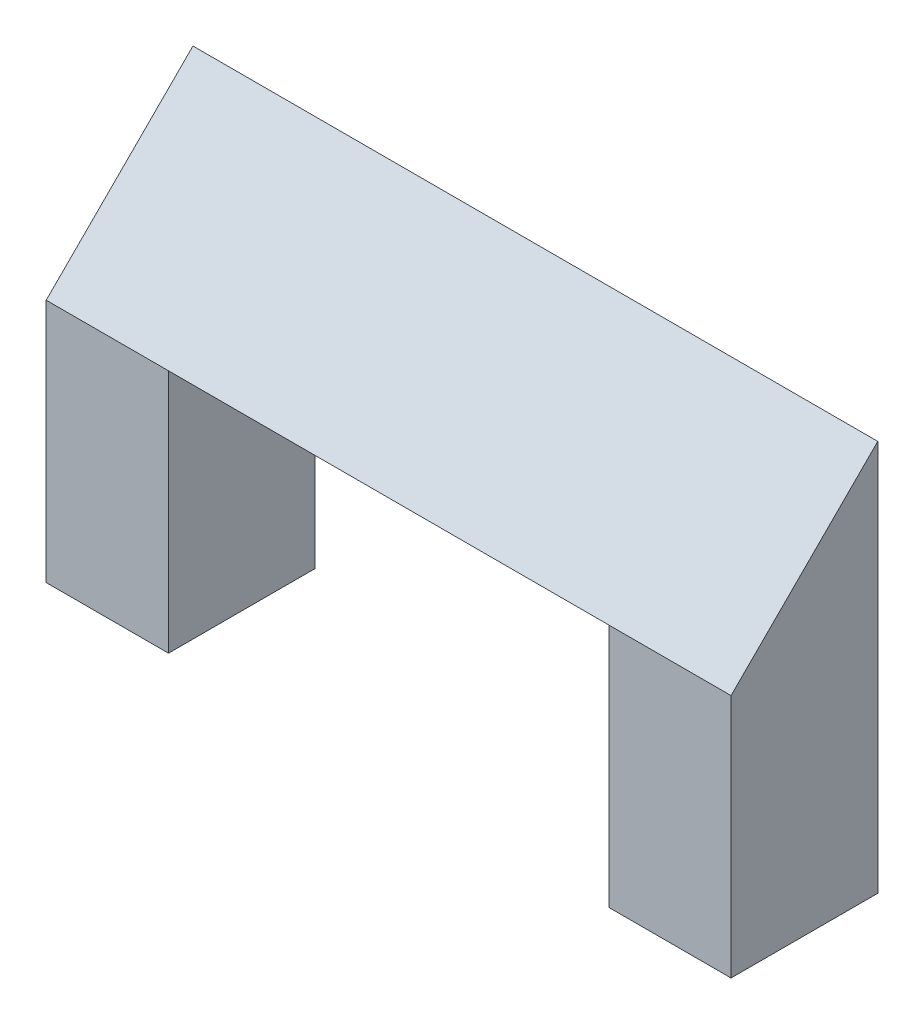
from build123d import *

# Parameters (mm, degrees)
SKETCH1_W             = 25
SKETCH1_H             = 30
BOSS_EXTRUDE1_DEPTH   = 50
BOSS_EXTRUDE1_2_DEPTH = 50
BOSS_EXTRUDE2_START   = -140
BOSS_EXTRUDE2_DEPTH   = 140
BOSS_EXTRUDE3_DEPTH   = 90


with BuildPart() as part:
    # Sketch1 → Boss-Extrude1 (new body)
    with BuildSketch(Plane(origin=(0, 0, 0), x_dir=(1, 0, 0), z_dir=(0, 1, 0))):
        with Locations((-31.032110092, 2.339449541)):
            Rectangle(SKETCH1_W, SKETCH1_H)
    extrude(amount=BOSS_EXTRUDE1_DEPTH)



with BuildPart() as body_2:
    # Sketch1 → Boss-Extrude1 2 (new body)
    with BuildSketch(Plane(origin=(0, 0, 0), x_dir=(1, 0, 0), z_dir=(0, 1, 0))):
        with Locations((83.967889908, 2.339449541)):
            Rectangle(SKETCH1_W, SKETCH1_H)
    extrude(amount=BOSS_EXTRUDE1_2_DEPTH)


with BuildPart() as part_1:
    add(part.part)

    add(body_2.part)  # Boss-Extrude2 merges body 2
    # Sketch2 → Boss-Extrude2 (add)
    with BuildSketch(Plane(origin=(96.467889908, 0, 0), x_dir=(0, 0, -1), z_dir=(1, 0, 0)).offset(BOSS_EXTRUDE2_START)):
        Polygon((-12.660550459, 50), (17.339449541, 50), (17.339449541, 80), align=None)
    extrude(amount=BOSS_EXTRUDE2_DEPTH)

    # Sketch3 → Boss-Extrude3 (add)
    with BuildSketch(Plane(origin=(-18.532110092, 0, 0), x_dir=(0, 0, -1), z_dir=(1, 0, 0))):
        Polygon((-12.660550459, 50), (17.339449541, 39.080892972), (17.339449541, 50), align=None)
    extrude(amount=BOSS_EXTRUDE3_DEPTH)


solid = part_1.part
